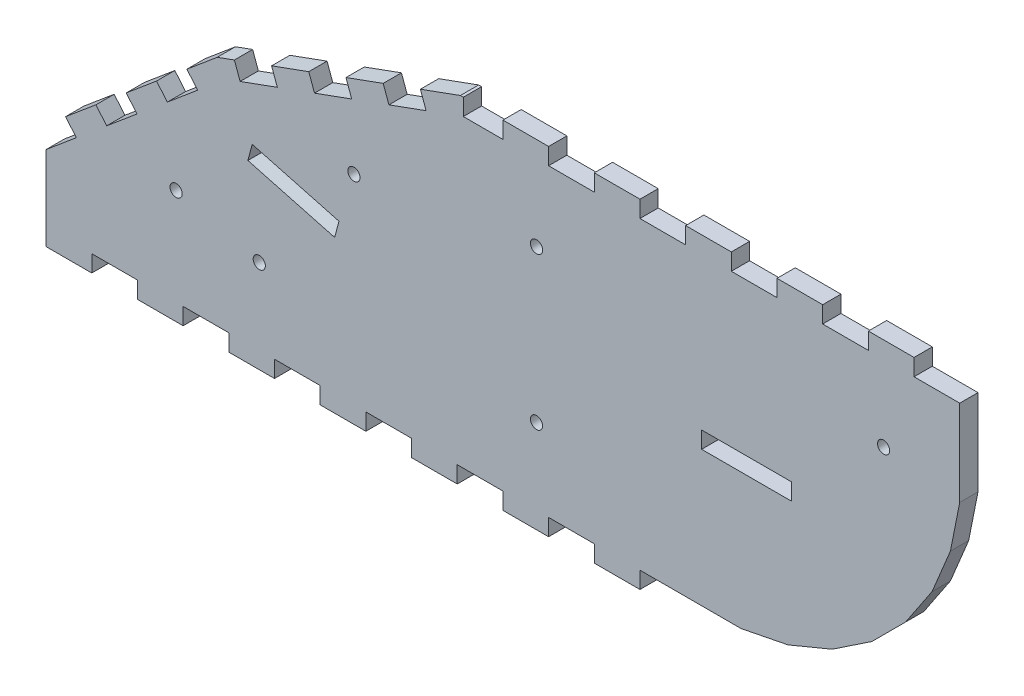
from build123d import *

# Parameters (mm, degrees)
MODEL_R             = 2
MODEL_W             = 29.5
MODEL_H             = 5.5
BOSS_EXTRUDE1_DEPTH = 6


with BuildPart() as part:
    # Model → Boss-Extrude1 (new body)
    with BuildSketch(Plane.XY):
        Polygon((41.305703545, 60.317480411), (37.765395693, 64.536655013), (47.723769702, 72.891019085), (51.262213555, 68.676185328), (61.217679315, 77.034013574), (57.683186462, 81.246258129), (67.640721471, 89.601622083), (73.284512173, 91.655793907), (75.16331879, 86.492201925), (87.378490159, 90.936771689), (85.497379371, 96.105081103), (97.712550739, 100.549650868), (99.594494229, 95.383033552), (111.809665598, 99.827603316), (109.92855481, 104.995912731), (122.143726178, 109.440482495), (124.025669668, 104.27386518), (136.240841037, 108.718434944), (134.359730249, 113.886744358), (147.487562001, 118.663391555), (148.455483892, 118.663391555), (148.455483892, 113.163391555), (161.455483892, 113.163391555), (161.455483892, 118.663391555), (176.455483892, 118.663391555), (176.455483892, 113.163391555), (191.455483892, 113.163391555), (191.455483892, 118.663391555), (206.455483892, 118.663391555), (206.455483892, 113.163391555), (221.455483892, 113.163391555), (221.455483892, 118.663391555), (236.455483892, 118.663391555), (236.455483892, 113.163391555), (251.455483892, 113.163391555), (251.455483892, 118.663391555), (266.455483892, 118.663391555), (266.455483892, 113.163391555), (281.455483892, 113.163391555), (281.455483892, 118.663391555), (296.455483892, 118.663391555), (296.455483892, 113.163391555), (311.455483892, 113.163391555), (311.455483892, 100.619540915), (311.455483892, 84.936798462), (308.395932616, 69.555395508), (302.394406906, 55.066430742), (293.681542027, 42.026706955), (282.592168491, 30.937333419), (269.552444704, 22.224468541), (255.063479938, 16.22294283), (239.682076984, 13.163391555), (236.455483892, 13.163391555), (221.455483892, 13.163391555), (206.455483892, 13.163391555), (206.455483892, 7.663391555), (191.455483892, 7.663391555), (191.455483892, 13.163391555), (176.455483892, 13.163391555), (176.455483892, 7.663391555), (161.455483892, 7.663391555), (161.455483892, 13.163391555), (146.455483892, 13.163391555), (146.455483892, 7.663391555), (131.455483892, 7.663391555), (131.455483892, 13.163391555), (116.455483892, 13.163391555), (116.455483892, 7.663391555), (101.455483892, 7.663391555), (101.455483892, 13.163391555), (86.455483892, 13.163391555), (86.455483892, 7.663391555), (71.455483892, 7.663391555), (71.455483892, 13.163391555), (56.455483892, 13.163391555), (56.455483892, 7.663391555), (41.455483892, 7.663391555), (41.455483892, 13.163391555), (26.455483892, 13.163391555), (26.455483892, 7.663391555), (11.425401767, 7.663391555), (11.425401767, 35.258443505), (21.383775776, 43.612807577), (17.848443923, 47.826052014), (27.806817932, 56.180416087), (31.342353537, 51.969046503), align=None)
        with Locations((172.487562001, 88.163391555)):
            Circle(MODEL_R, mode=Mode.SUBTRACT)
        with Locations((286.455483892, 88.163391555)):
            Circle(MODEL_R, mode=Mode.SUBTRACT)
        with Locations((81.455483892, 38.163391555)):
            Circle(MODEL_R, mode=Mode.SUBTRACT)
        with Locations((172.487562001, 38.163391555)):
            Circle(MODEL_R, mode=Mode.SUBTRACT)
        with Locations((112.543046266, 78.812365745)):
            Circle(MODEL_R, mode=Mode.SUBTRACT)
        with Locations((54.155009637, 45.002140534)):
            Circle(MODEL_R, mode=Mode.SUBTRACT)
        with Locations((241.455483892, 60.413391555)):
            Rectangle(MODEL_W, MODEL_H, mode=Mode.SUBTRACT)
        Polygon((107.62898864, 62.975983599), (79.134176764, 70.61114543), (77.710672016, 65.298553385), (106.205483892, 57.663391555), align=None, mode=Mode.SUBTRACT)
    extrude(amount=BOSS_EXTRUDE1_DEPTH)


solid = part.part
